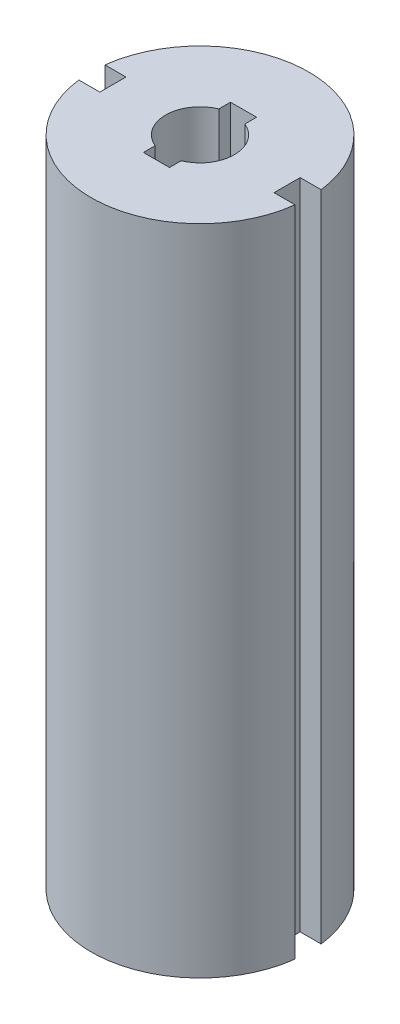
from build123d import *

# Parameters (mm, degrees)
BOSS_EXTRUDE1_DEPTH = 19.05
CUT_EXTRUDE1_DEPTH  = 7.62


with BuildPart() as part:
    # Sketch1 → Boss-Extrude1 (new body)
    with BuildSketch(Plane(origin=(0, 0, 0), x_dir=(1, 0, 0), z_dir=(0, 1, 0))):
        with BuildLine():
            Line((2.54, -0.381), (3.152057106, -0.381))
            ThreePointArc((3.152057106, -0.381), (0, -3.175), (-3.152057106, -0.381))
            Line((-3.152057106, -0.381), (-2.54, -0.381))
            Line((-2.54, -0.381), (-2.54, 0.381))
            Line((-2.54, 0.381), (-3.152057106, 0.381))
            ThreePointArc((-3.152057106, 0.381), (0, 3.175), (3.152057106, 0.381))
            Line((3.152057106, 0.381), (2.54, 0.381))
            Line((2.54, 0.381), (2.54, -0.381))
        make_face()
    extrude(amount=BOSS_EXTRUDE1_DEPTH)

    # Sketch2 → Cut-Extrude1 (cut)
    with BuildSketch(Plane(origin=(0, 19.05, 0), x_dir=(1, 0, 0), z_dir=(0, 1, 0))):
        with BuildLine():
            Line((-0.380189943, 0.928475362), (-0.380189943, 1.27))
            Line((-0.380189943, 1.27), (0.380189943, 1.27))
            Line((0.380189943, 1.27), (0.380189943, 0.928475362))
            ThreePointArc((0.380189943, 0.928475362), (1.0033, 0), (0.380189943, -0.928475362))
            Line((0.380189943, -0.928475362), (0.380189943, -1.27))
            Line((0.380189943, -1.27), (-0.380189943, -1.27))
            Line((-0.380189943, -1.27), (-0.380189943, -0.928475362))
            ThreePointArc((-0.380189943, -0.928475362), (-1.0033, 0), (-0.380189943, 0.928475362))
        make_face()
    extrude(amount=-CUT_EXTRUDE1_DEPTH, mode=Mode.SUBTRACT)


solid = part.part
